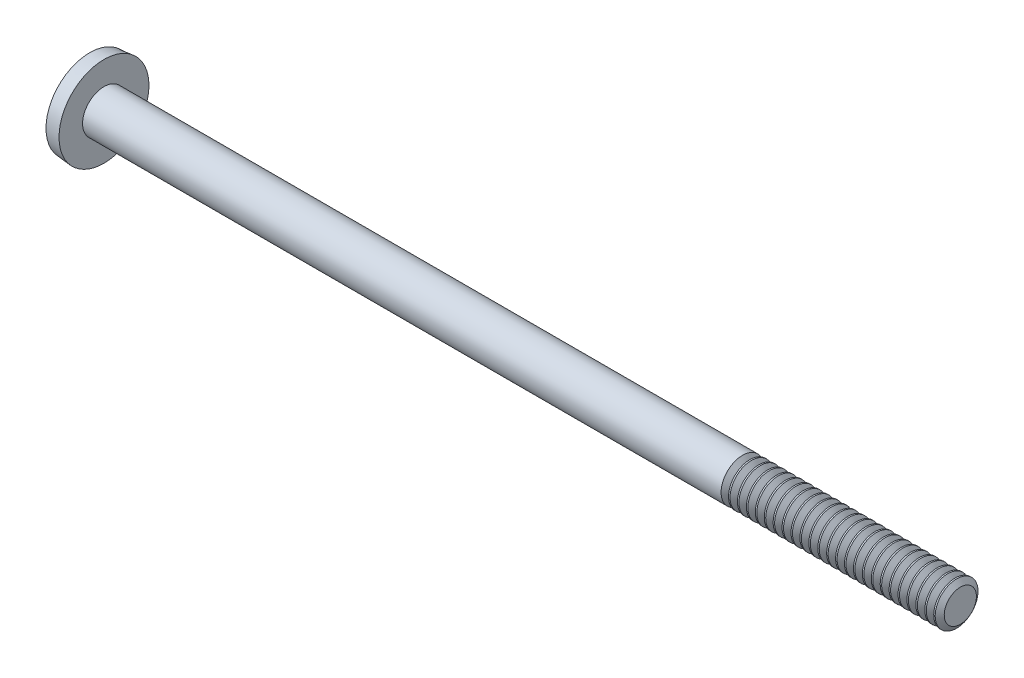
from build123d import *

# Parameters (mm, degrees)
SKETCH3_W         = 0.5842
SKETCH3_H         = 2.1082
SKETCH4_W         = 0.2921
SKETCH4_H         = 0.2921
CIRPATTERN1_COUNT = 2
CIRPATTERN1_ANGLE = 90
THDSCHPAT_COUNT   = 25
THDSCHPAT_PITCH   = 0.3175


with BuildPart() as part:
    # BodySke → Base-Revolve (revolve)
    with BuildSketch(Plane.XY):
        with BuildLine():
            Line((0.8128, 0.762), (0.8128, 1.6002))
            Line((0.8128, 1.6002), (0.3048, 1.555755759))
            ThreePointArc((0.3048, 1.555755759), (0.076917504, 0.792666232), (0, 0))
            Line((0, 0), (31.2928, 0))
            Line((31.2928, 0), (31.2928, 0.762))
            Line((31.2928, 0.762), (0.8128, 0.762))
        make_face()
    revolve(axis=Axis((-25.4, 0, 0), (1, 0, 0)))

    # Sketch3 → Cross section 0
    with BuildSketch(Plane(origin=(0, 0, 0), x_dir=(0, 0, -1), z_dir=(1, 0, 0))):
        Rectangle(SKETCH3_W, SKETCH3_H)
    # Sketch4 → Cross section 1
    with BuildSketch(Plane(origin=(1.0668, 0, 0), x_dir=(0, 0, -1), z_dir=(1, 0, 0))):
        Rectangle(SKETCH4_W, SKETCH4_H)
    cross = loft(mode=Mode.SUBTRACT)

    # CirPattern1: Cross ×2 about axis
    cirpattern1_axis = Axis((0, 0, 0), (1, 0, 0))
    for i in range(1, CIRPATTERN1_COUNT):
        add(cross.rotate(cirpattern1_axis, i * CIRPATTERN1_ANGLE / (CIRPATTERN1_COUNT - 1)), mode=Mode.SUBTRACT)

    # ThdSchSke → ThreadSchematic (revolve, cut)
    with BuildSketch(Plane.XY):
        Polygon((23.6728, -0.57277), (23.540299728, -0.762), (23.540299728, -0.9525), (23.805300272, -0.9525), (23.805300272, -0.762), align=None)
    threadschematic = revolve(axis=Axis((-3.175, 0, 0), (1, 0, 0)), mode=Mode.SUBTRACT)

    # ThdSchPat: ThreadSchematic ×25
    with Locations(*[(i * THDSCHPAT_PITCH, 0, 0) for i in range(1, THDSCHPAT_COUNT)]):
        add(threadschematic, mode=Mode.SUBTRACT)


solid = part.part
